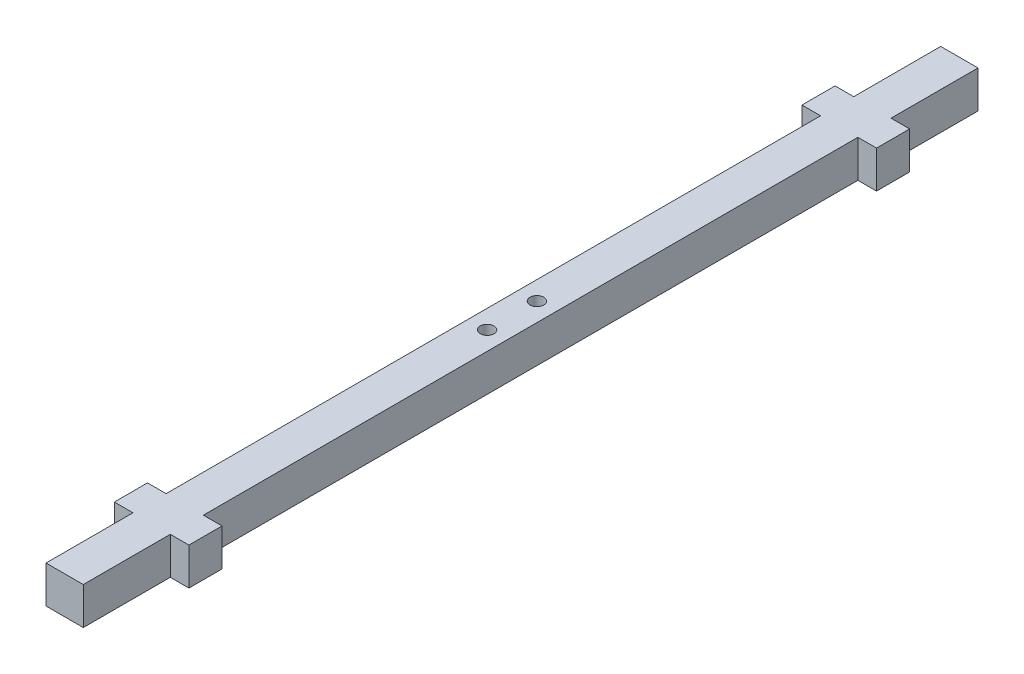
from build123d import *

# Parameters (mm, degrees)
SKETCH1_W               = 9
SKETCH1_H               = 9
BOSS_EXTRUDE1_DEPTH     = 108
SKETCH2_W               = 18
SKETCH2_H               = 8
BOSS_EXTRUDE2_DEPTH     = 4.5
SKETCH3_R               = 1.65
CUT_EXTRUDE1_DEPTH      = 1
CUT_EXTRUDE1_DEPTH_BACK = 10


with BuildPart() as part:
    # Sketch1 → Boss-Extrude1 (new body, symmetric)
    with BuildSketch(Plane.XY):
        Rectangle(SKETCH1_W, SKETCH1_H)
    extrude(amount=BOSS_EXTRUDE1_DEPTH, both=True)

    # Sketch2 → Boss-Extrude2 (add, symmetric)
    with BuildSketch(Plane(origin=(0, 0, 0), x_dir=(1, 0, 0), z_dir=(0, 1, 0))):
        with Locations((0, 83)):
            Rectangle(SKETCH2_W, SKETCH2_H)
        with Locations((0, -83)):
            Rectangle(SKETCH2_W, SKETCH2_H)
    extrude(amount=BOSS_EXTRUDE2_DEPTH, both=True)

    # Sketch3 → Cut-Extrude1 (cut, two sides)
    with BuildSketch(Plane(origin=(0, 4.5, 0), x_dir=(1, 0, 0), z_dir=(0, 1, 0))) as cut_extrude1_sk:
        with Locations((0, 6)):
            Circle(SKETCH3_R)
        with Locations((0, -6)):
            Circle(SKETCH3_R)
    extrude(amount=CUT_EXTRUDE1_DEPTH, mode=Mode.SUBTRACT)
    extrude(cut_extrude1_sk.sketch, amount=-CUT_EXTRUDE1_DEPTH_BACK, mode=Mode.SUBTRACT)


solid = part.part
